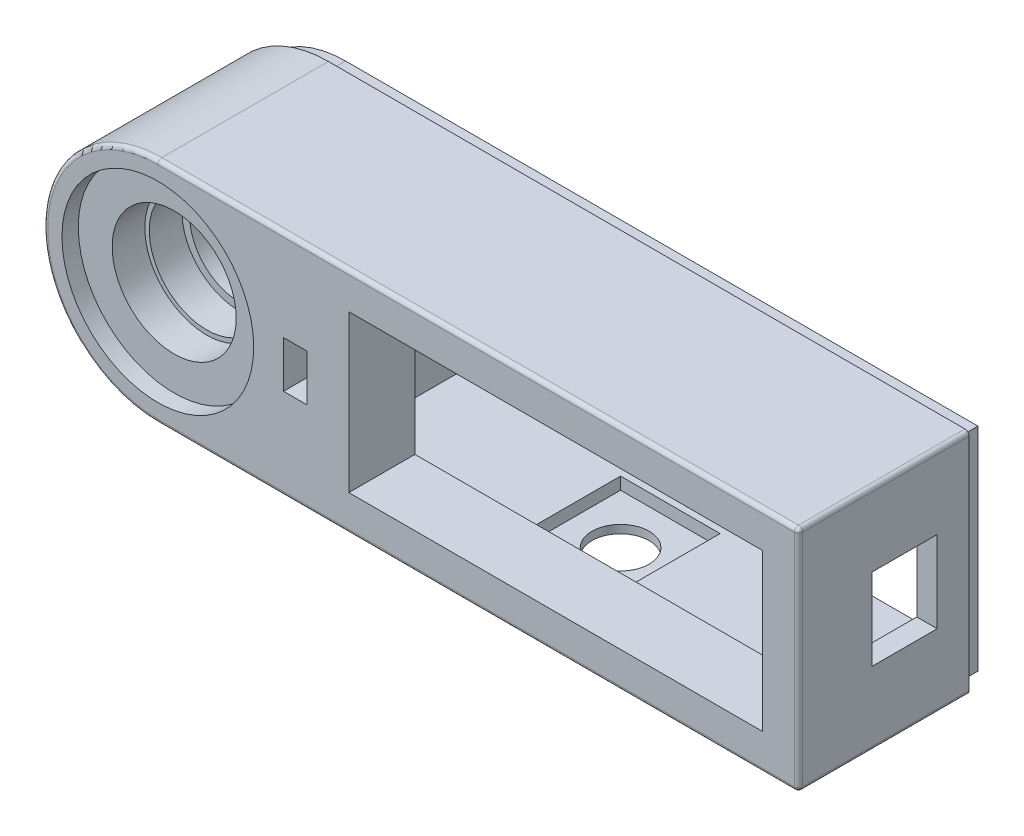
from build123d import *

# Parameters (mm, degrees)
EXTRUDE_1_DEPTH       = 23
SKETCH_2_R            = 11.75
CUT_EXTRUDE_1_DEPTH   = 2
SKETCH_3_R            = 7.6
CUT_EXTRUDE_2_DEPTH   = 4
SKETCH_4_R            = 7.05
CUT_EXTRUDE_3_DEPTH   = 4
SKETCH_5_R            = 6.1
CUT_EXTRUDE_4_DEPTH   = 4
SKETCH_6_R            = 2.6
CUT_EXTRUDE_5_DEPTH   = 9
SKETCH_7_R            = 2.95
CUT_EXTRUDE_6_DEPTH   = 1.1
SKETCH_8_W            = 50.7
SKETCH_8_H            = 19.2
CUT_EXTRUDE_7_DEPTH   = 8.1
SKETCH_9_W            = 60.5
SKETCH_9_H            = 23
CUT_EXTRUDE_8_DEPTH   = 14.9
CUT_EXTRUDE_9_REACH   = 94.5
SKETCH_10_W           = 8
SKETCH_10_H           = 10
CUT_EXTRUDE_1_2_DEPTH = 2.1
SKETCH_13_W           = 12.2
SKETCH_13_H           = 12.2
CUT_EXTRUDE_11_DEPTH  = 1.5
CUT_EXTRUDE_14_REACH  = 3
SKETCH_16_R           = 3.5
SKETCH_14_W           = 2.7
SKETCH_14_H           = 5.5
CUT_EXTRUDE_12_DEPTH  = 12
SKETCH_15_W           = 2.9
SKETCH_15_H           = 5.7
CUT_EXTRUDE_13_DEPTH  = 5.6
FILLET_1_R            = 0.5


with BuildPart() as part:
    # Эскиз1 → Бобышка-Вытянуть1 (new body)
    with BuildSketch(Plane.XY):
        with BuildLine():
            Line((39.25, -14), (-39.25, -14))
            ThreePointArc((-39.25, -14), (-53.25, 0), (-39.25, 14))
            Line((-39.25, 14), (39.25, 14))
            Line((39.25, 14), (39.25, -14))
        make_face()
    extrude(amount=EXTRUDE_1_DEPTH)

    # Эскиз2 → Cut-Extrude 1 (cut)
    with BuildSketch(Plane.XY.offset(23)):
        with Locations((-39.25, 0)):
            Circle(SKETCH_2_R)
    extrude(amount=-CUT_EXTRUDE_1_DEPTH, mode=Mode.SUBTRACT)

    # Эскиз3 → Вырез-Вытянуть2 (cut)
    with BuildSketch(Plane.XY.offset(21)):
        with Locations((-39.25, 0)):
            Circle(SKETCH_3_R)
    extrude(amount=-CUT_EXTRUDE_2_DEPTH, mode=Mode.SUBTRACT)

    # Эскиз4 → Вырез-Вытянуть3 (cut)
    with BuildSketch(Plane.XY.offset(17)):
        with Locations((-39.25, 0)):
            Circle(SKETCH_4_R)
    extrude(amount=-CUT_EXTRUDE_3_DEPTH, mode=Mode.SUBTRACT)

    # Эскиз5 → Вырез-Вытянуть4 (cut)
    with BuildSketch(Plane.XY.offset(13)):
        with Locations((-39.25, 0)):
            Circle(SKETCH_5_R)
    extrude(amount=-CUT_EXTRUDE_4_DEPTH, mode=Mode.SUBTRACT)

    # Эскиз6 → Вырез-Вытянуть5 (cut)
    with BuildSketch(Plane.XY.offset(9)):
        with Locations((-39.25, 0)):
            Circle(SKETCH_6_R)
    extrude(amount=-CUT_EXTRUDE_5_DEPTH, mode=Mode.SUBTRACT)

    # Эскиз7 → Вырез-Вытянуть6 (cut)
    with BuildSketch(Plane(origin=(0, 0, 0), x_dir=(-1, 0, 0), z_dir=(0, 0, -1))):
        with Locations((39.25, 0)):
            Circle(SKETCH_7_R)
    extrude(amount=-CUT_EXTRUDE_6_DEPTH, mode=Mode.SUBTRACT)

    # Эскиз8 → Вырез-Вытянуть7 (cut)
    with BuildSketch(Plane.XY.offset(23)):
        with Locations((9.5, 0)):
            Rectangle(SKETCH_8_W, SKETCH_8_H)
    extrude(amount=-CUT_EXTRUDE_7_DEPTH, mode=Mode.SUBTRACT)

    # Эскиз9 → Вырез-Вытянуть8 (cut)
    with BuildSketch(Plane(origin=(0, 0, 0), x_dir=(-1, 0, 0), z_dir=(0, 0, -1))):
        with Locations((-6.5, 0)):
            Rectangle(SKETCH_9_W, SKETCH_9_H)
    extrude(amount=-CUT_EXTRUDE_8_DEPTH, mode=Mode.SUBTRACT)

    # Эскиз10 → Вырез-Вытянуть9 (cut, up to next)
    with BuildSketch(Plane(origin=(39.25, 0, 0), x_dir=(0, 0, -1), z_dir=(1, 0, 0)), mode=Mode.PRIVATE) as cut_extrude_9_sk1:
        with Locations((-10, 0)):
            Rectangle(SKETCH_10_W, SKETCH_10_H)
    cut_extrude_9_tool1 = extrude(cut_extrude_9_sk1.sketch, amount=-CUT_EXTRUDE_9_REACH, mode=Mode.PRIVATE) & part.part
    add(cut_extrude_9_tool1.solids().sort_by_distance((39.25, 0, 10))[0], mode=Mode.SUBTRACT)

    # Эскиз11 → Cut-Extrude 1 2 (cut)
    with BuildSketch(Plane(origin=(0, 0, 0), x_dir=(-1, 0, 0), z_dir=(0, 0, -1))):
        with BuildLine():
            Line((39.25, 15), (-40.25, 15))
            Line((-40.25, 15), (-40.25, -15))
            Line((-40.25, -15), (39.25, -15))
            ThreePointArc((39.25, -15), (54.25, 0), (39.25, 15))
        make_face()
        with BuildLine():
            Line((39.25, 13), (-38.25, 13))
            Line((-38.25, 13), (-38.25, -13))
            Line((-38.25, -13), (39.25, -13))
            ThreePointArc((39.25, -13), (52.25, 0), (39.25, 13))
        make_face(mode=Mode.SUBTRACT)
    extrude(amount=-CUT_EXTRUDE_1_2_DEPTH, mode=Mode.SUBTRACT)

    # Эскиз13 → Вырез-Вытянуть11 (cut)
    with BuildSketch(Plane(origin=(0, -11.5, 0), x_dir=(1, 0, 0), z_dir=(0, 1, 0))):
        with Locations((3.25, -8.8)):
            Rectangle(SKETCH_13_W, SKETCH_13_H)
    extrude(amount=-CUT_EXTRUDE_11_DEPTH, mode=Mode.SUBTRACT)

    # Эскиз16 → Вырез-Вытянуть14 (cut, up to next)
    with BuildSketch(Plane(origin=(0, -13, 0), x_dir=(1, 0, 0), z_dir=(0, 1, 0)), mode=Mode.PRIVATE) as cut_extrude_14_sk1:
        with Locations((3.25, -8.8)):
            Circle(SKETCH_16_R)
    cut_extrude_14_tool1 = extrude(cut_extrude_14_sk1.sketch, amount=-CUT_EXTRUDE_14_REACH, mode=Mode.PRIVATE) & part.part
    add(cut_extrude_14_tool1.solids().sort_by_distance((3.25, -13, 8.8))[0], mode=Mode.SUBTRACT)

    # Эскиз14 → Вырез-Вытянуть12 (cut)
    with BuildSketch(Plane(origin=(0, 0, 14.9), x_dir=(-1, 0, 0), z_dir=(0, 0, -1))):
        with Locations((22.4, 0)):
            Rectangle(SKETCH_14_W, SKETCH_14_H)
    extrude(amount=-CUT_EXTRUDE_12_DEPTH, mode=Mode.SUBTRACT)

    # Эскиз15 → Вырез-Вытянуть13 (cut)
    with BuildSketch(Plane.XY.offset(23)):
        with Locations((-22.4, 0)):
            Rectangle(SKETCH_15_W, SKETCH_15_H)
    extrude(amount=-CUT_EXTRUDE_13_DEPTH, mode=Mode.SUBTRACT)

    # Скругление1
    fillet_1_edges = [part.edges().sort_by_distance(p)[0] for p in [
        (39.25, 0, 23),
        (0, 14, 23),
        (-53.25, 0, 23),
        (0, -14, 23),
        (39.25, 14, 12.55),
        (39.25, -14, 12.55),
    ]]
    fillet(fillet_1_edges, radius=FILLET_1_R)


solid = part.part
